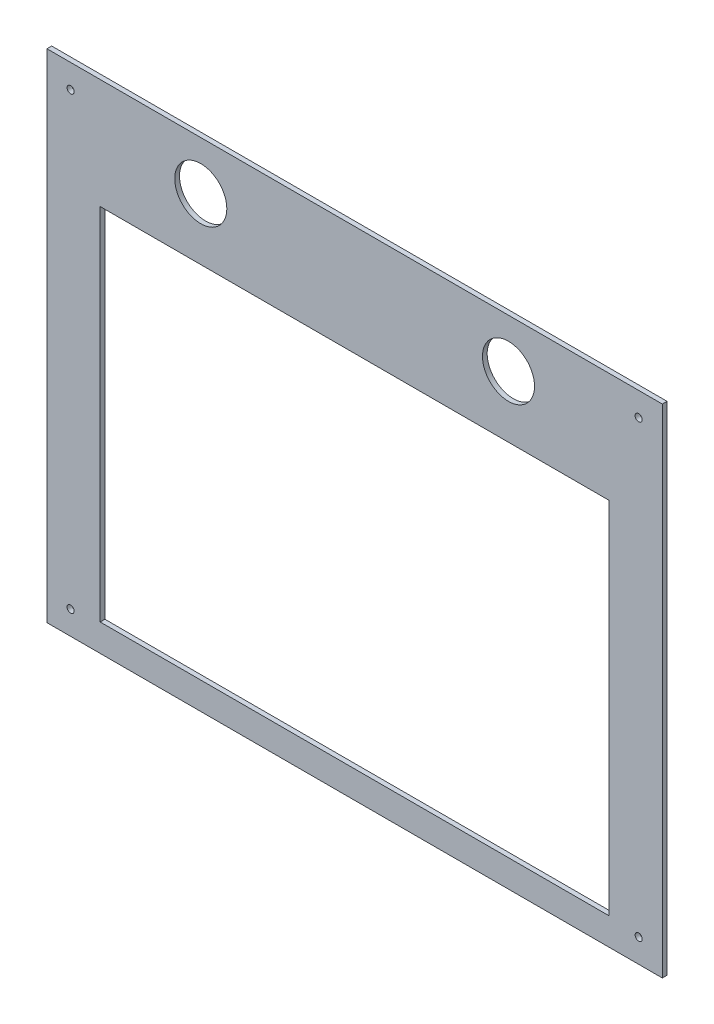
from build123d import *

# Parameters (mm, degrees)
SKETCH_1_W          = 260
SKETCH_1_H          = 210
EXTRUDE_1_DEPTH     = 2
SKETCH_2_R          = 11
CUT_EXTRUDE_1_DEPTH = 2
SKETCH_3_R          = 1.5
CUT_EXTRUDE_2_DEPTH = 2
SKETCH_4_R          = 1.5
CUT_EXTRUDE_3_DEPTH = 10


with BuildPart() as part:
    # 草图1 → 凸台-拉伸1 (new body)
    with BuildSketch(Plane.XY):
        with Locations((130, 105)):
            Rectangle(SKETCH_1_W, SKETCH_1_H)
    extrude(amount=EXTRUDE_1_DEPTH)

    # 草图2 → 切除-拉伸1 (cut)
    with BuildSketch(Plane.XY.offset(2)):
        with Locations((65, 189.471035353)):
            Circle(SKETCH_2_R)
        with Locations((195, 189.471035353)):
            Circle(SKETCH_2_R)
        Polygon((130, 11.510265982), (22.5, 11.510265982), (22.5, 163.510265982), (237.5, 163.510265982), (237.5, 11.510265982), align=None)
    extrude(amount=-CUT_EXTRUDE_1_DEPTH, mode=Mode.SUBTRACT)

    # 草图3 → 切除-拉伸2 (cut)
    with BuildSketch(Plane.XY.offset(2)):
        with Locations((250, 230)):
            Circle(SKETCH_3_R)
        with Locations((10, 10)):
            Circle(SKETCH_3_R)
        with Locations((250, 10)):
            Circle(SKETCH_3_R)
        with Locations((10, 230)):
            Circle(SKETCH_3_R)
    extrude(amount=-CUT_EXTRUDE_2_DEPTH, mode=Mode.SUBTRACT)

    # 草图4 → 切除-拉伸3 (cut)
    with BuildSketch(Plane.XY.offset(2)):
        with Locations((10, 200)):
            Circle(SKETCH_4_R)
        with Locations((250, 200)):
            Circle(SKETCH_4_R)
    extrude(amount=-CUT_EXTRUDE_3_DEPTH, mode=Mode.SUBTRACT)


solid = part.part
